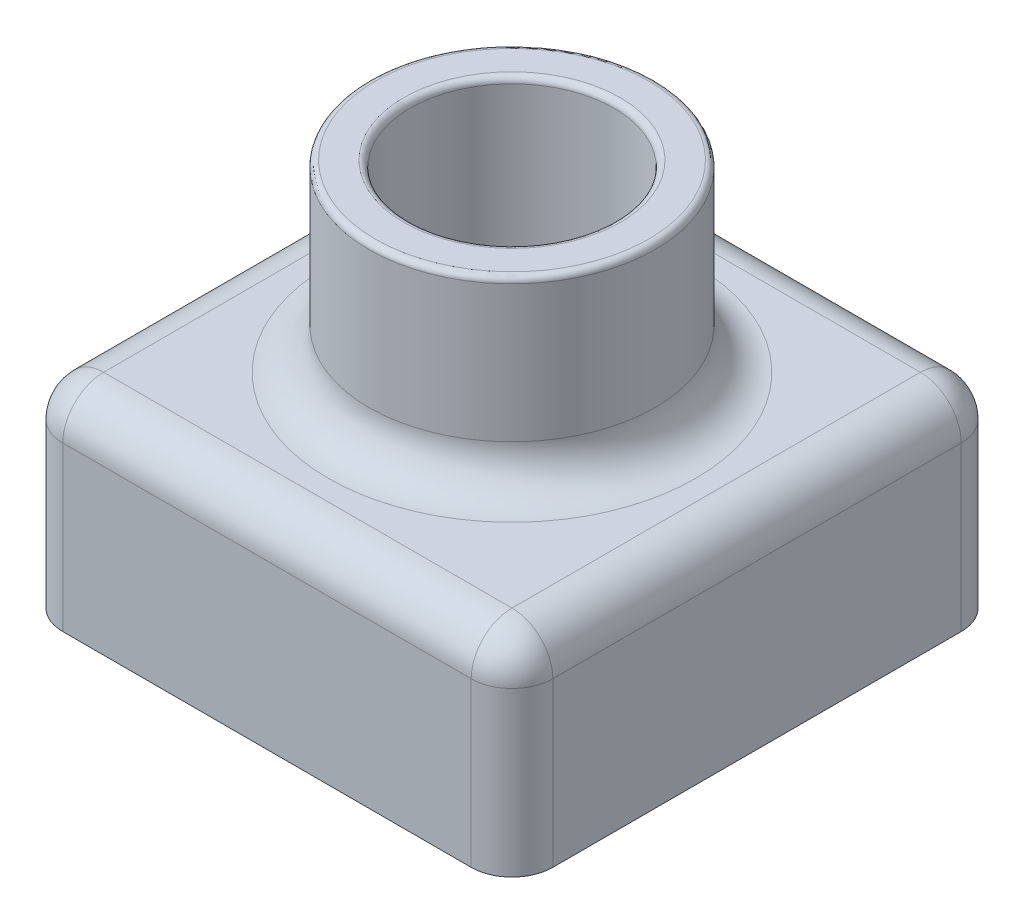
from build123d import *

# Parameters (mm, degrees)
SKETCH3_W           = 120
SKETCH3_H           = 120
BOSS_EXTRUDE2_DEPTH = 50
SKETCH4_R           = 35
BOSS_EXTRUDE3_DEPTH = 45
SKETCH9_R           = 25
CUT_EXTRUDE3_DEPTH  = 195.486503388
FILLET4_R           = 10
FILLET5_R           = 1.5
SHELL2_T            = -2


with BuildPart() as part:
    # Sketch3 → Boss-Extrude2 (new body)
    with BuildSketch(Plane(origin=(0, 0, 0), x_dir=(1, 0, 0), z_dir=(0, 1, 0))):
        with Locations((60, 60)):
            Rectangle(SKETCH3_W, SKETCH3_H)
    extrude(amount=BOSS_EXTRUDE2_DEPTH)

    # Sketch4 → Boss-Extrude3 (add)
    with BuildSketch(Plane(origin=(0, 50, 0), x_dir=(1, 0, 0), z_dir=(0, 1, 0))):
        with Locations(Location((60, 60, 0), (0, 0, 90))):
            Circle(SKETCH4_R)
    extrude(amount=BOSS_EXTRUDE3_DEPTH)

    # Sketch9 → Cut-Extrude3 (cut, through all)
    with BuildSketch(Plane(origin=(0, 95, 0), x_dir=(1, 0, 0), z_dir=(0, 1, 0))):
        with Locations(Location((60, 60, 0), (0, 0, 270))):
            Circle(SKETCH9_R)
    extrude(amount=-CUT_EXTRUDE3_DEPTH, mode=Mode.SUBTRACT)

    # Fillet4
    fillet4_edges = [part.edges().sort_by_distance(p)[0] for p in [
        (60, 50, 0),
        (60, 50, -25),
        (0, 50, -60),
        (60, 50, -120),
        (0, 25, -120),
        (0, 25, 0),
        (120, 25, 0),
        (120, 25, -120),
        (120, 50, -60),
    ]]
    fillet(fillet4_edges, radius=FILLET4_R)

    # Fillet5
    fillet5_edges = [part.edges().sort_by_distance(p)[0] for p in [
        (60, 95, -25),
        (60, 95, -85),
    ]]
    fillet(fillet5_edges, radius=FILLET5_R)

    # Shell2
    shell2_openings = [part.faces().sort_by_distance(p)[0] for p in [
        (60, 0, -1.697056275),
    ]]
    offset(amount=SHELL2_T, openings=shell2_openings, kind=Kind.INTERSECTION)


solid = part.part
